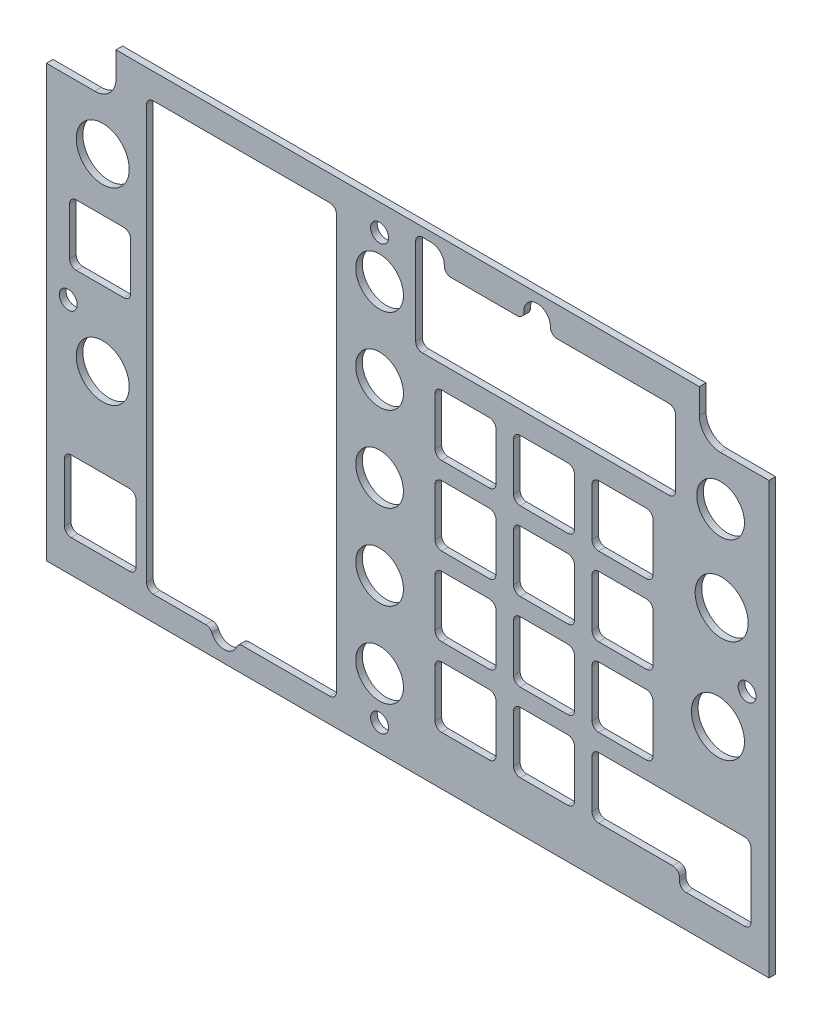
from build123d import *

# Parameters (mm, degrees)
BOSS_EXTRUDE1_DEPTH         = 1.5875
SKETCH2_R                   = 6.35
SKETCH2_R_2                 = 5.715
SKETCH2_W                   = 14.605
SKETCH2_H                   = 14.605
SKETCH2_W_2                 = 17.145
SKETCH2_H_2                 = 17.145
SKETCH2_W_3                 = 62.23
SKETCH2_H_3                 = 19.05
SKETCH2_W_4                 = 45.462
SKETCH2_H_4                 = 102.32
CUT_EXTRUDE1_DEPTH          = 2.5875
F_6_CLEARANCE_HOLE2_D       = 4.3053
F_1_4_0_25_DIAMETER_HOLE1_D = 6.35
CUT_EXTRUDE3_DEPTH          = 2.5875
FILLET1_R                   = 1.5875
FILLET2_R                   = 1.5875


with BuildPart() as part:
    # Sketch1 → Boss-Extrude1 (new body)
    with BuildSketch(Plane.XY):
        with BuildLine():
            Line((58.206752076, 169.534029068), (58.206752076, 175.566529068))
            Line((58.206752076, 175.566529068), (-81.493247924, 175.566529068))
            Line((-81.493247924, 175.566529068), (-81.493247924, 169.534029068))
            ThreePointArc((-81.493247924, 169.534029068), (-82.981145475, 165.941926619), (-86.573247924, 164.454029068))
            Line((-86.573247924, 164.454029068), (-98.161997924, 164.454029068))
            Line((-98.161997924, 164.454029068), (-98.161997924, 61.266529068))
            Line((-98.161997924, 61.266529068), (74.875502076, 61.266529068))
            Line((74.875502076, 61.266529068), (74.875502076, 164.454029068))
            Line((74.875502076, 164.454029068), (63.286752076, 164.454029068))
            ThreePointArc((63.286752076, 164.454029068), (59.694649628, 165.941926619), (58.206752076, 169.534029068))
        make_face()
    extrude(amount=BOSS_EXTRUDE1_DEPTH)

    # Sketch2 → Cut-Extrude1 (cut, through all)
    with BuildSketch(Plane.XY.offset(1.5875)):
        with Locations((-84.668247924, 152.389029068)):
            Circle(SKETCH2_R)
        with Locations((-84.668247924, 107.304029068)):
            Circle(SKETCH2_R)
        with Locations((63.540752076, 132.386529068)):
            Circle(SKETCH2_R)
        with Locations((62.651752076, 107.304029068)):
            Circle(SKETCH2_R)
        with Locations((-18.374247924, 77.776529068)):
            Circle(SKETCH2_R_2)
        with Locations((-18.374247924, 98.096529068)):
            Circle(SKETCH2_R_2)
        with Locations((-18.374247924, 118.416529068)):
            Circle(SKETCH2_R_2)
        with Locations((-18.374247924, 138.736529068)):
            Circle(SKETCH2_R_2)
        with Locations((-18.374247924, 159.056529068)):
            Circle(SKETCH2_R_2)
        with Locations((63.286752076, 152.706529068)):
            Circle(SKETCH2_R_2)
        with Locations((39.791752076, 136.704529068)):
            Rectangle(SKETCH2_W, SKETCH2_H)
        with Locations((62.004966978, 77.649529068)):
            Rectangle(SKETCH2_W_2, SKETCH2_H_2)
        with Locations((20.995752076, 136.704529068)):
            Rectangle(SKETCH2_W, SKETCH2_H)
        with Locations((2.199752076, 136.704529068)):
            Rectangle(SKETCH2_W, SKETCH2_H)
        with Locations((21.376752076, 158.929529068)):
            Rectangle(SKETCH2_W_3, SKETCH2_H_3)
        with Locations((39.791752076, 80.316529068)):
            Rectangle(SKETCH2_W, SKETCH2_H)
        with Locations((39.791752076, 99.112529068)):
            Rectangle(SKETCH2_W, SKETCH2_H)
        with Locations((39.791752076, 117.908529068)):
            Rectangle(SKETCH2_W, SKETCH2_H)
        with Locations((20.995752076, 80.316529068)):
            Rectangle(SKETCH2_W, SKETCH2_H)
        with Locations((-85.255785181, 77.63300664)):
            Rectangle(SKETCH2_W_2, SKETCH2_H_2)
        with Locations((20.995752076, 99.112529068)):
            Rectangle(SKETCH2_W, SKETCH2_H)
        with Locations((20.995752076, 117.908529068)):
            Rectangle(SKETCH2_W, SKETCH2_H)
        with Locations((2.199752076, 117.908529068)):
            Rectangle(SKETCH2_W, SKETCH2_H)
        with Locations((2.199752076, 99.112529068)):
            Rectangle(SKETCH2_W, SKETCH2_H)
        with Locations((2.199752076, 80.316529068)):
            Rectangle(SKETCH2_W, SKETCH2_H)
        with Locations((-85.303247924, 132.386529068)):
            Rectangle(SKETCH2_W, SKETCH2_H)
        with Locations((-51.442247924, 118.289529068)):
            Rectangle(SKETCH2_W_4, SKETCH2_H_4)
    extrude(amount=-CUT_EXTRUDE1_DEPTH, mode=Mode.SUBTRACT)

    # #6 Clearance Hole2 (through all)
    with Locations(Plane(origin=(-11.643247924, -6.662700632, -3.175), x_dir=(-1, 0, 0), z_dir=(0, 0, -1))):
        with Locations((-81.28, 124.6982297), (6.731, 175.8792297), (81.28, 124.6982297), (6.731, 74.2792297)):
            Hole(F_6_CLEARANCE_HOLE2_D / 2)

    # 1/4 (0.25) Diameter Hole1 (through all)
    with Locations(Plane(origin=(0, 0, 0), x_dir=(-1, 0, 0), z_dir=(0, 0, -1))):
        with Locations((55.583247924, 67.341529068), (-49.826752076, 81.946529068), (-19.346752076, 170.211529068), (6.053247924, 170.211529068)):
            Hole(F_1_4_0_25_DIAMETER_HOLE1_D / 2)

    # Sketch10 → Cut-Extrude3 (cut, through all)
    with BuildSketch(Plane(origin=(0, 0, 0), x_dir=(-1, 0, 0), z_dir=(0, 0, -1))):
        with BuildLine():
            Line((9.738247924, 168.454529068), (9.738247924, 173.386529068))
            Line((9.738247924, 173.386529068), (6.053247924, 173.386529068))
            ThreePointArc((6.053247924, 173.386529068), (8.85138123, 171.711887358), (8.697784934, 168.454529068))
            Line((8.697784934, 168.454529068), (9.738247924, 168.454529068))
        make_face()
        Polygon((-47.094252076, 87.619029068), (-47.094252076, 73.014029068), (-53.432466978, 73.014029068), (-53.432466978, 86.222029068), (-70.577466978, 86.222029068), (-70.577466978, 87.619029068), align=None)
    extrude(amount=-CUT_EXTRUDE3_DEPTH, mode=Mode.SUBTRACT)

    # Fillet1
    fillet1_edges = [part.edges().sort_by_distance(p)[0] for p in [
        (9.502252076, 106.415029068, 0.79375),
        (9.502252076, 91.810029068, 0.79375),
        (-5.102747924, 91.810029068, 0.79375),
        (-5.102747924, 106.415029068, 0.79375),
        (9.502252076, 87.619029068, 0.79375),
        (9.502252076, 73.014029068, 0.79375),
        (-5.102747924, 73.014029068, 0.79375),
        (-5.102747924, 87.619029068, 0.79375),
        (-92.605747924, 125.084029068, 0.79375),
        (-92.605747924, 139.689029068, 0.79375),
        (-78.000747924, 139.689029068, 0.79375),
        (-78.000747924, 125.084029068, 0.79375),
        (-28.711247924, 169.449529068, 0.79375),
        (-28.711247924, 67.129529068, 0.79375),
        (-74.173247924, 67.129529068, 0.79375),
        (-74.173247924, 169.449529068, 0.79375),
        (32.489252076, 73.014029068, 0.79375),
        (32.489252076, 87.619029068, 0.79375),
        (47.094252076, 106.415029068, 0.79375),
        (47.094252076, 91.810029068, 0.79375),
        (32.489252076, 91.810029068, 0.79375),
        (32.489252076, 106.415029068, 0.79375),
        (47.094252076, 125.211029068, 0.79375),
        (47.094252076, 110.606029068, 0.79375),
        (32.489252076, 110.606029068, 0.79375),
        (32.489252076, 125.211029068, 0.79375),
        (28.298252076, 144.007029068, 0.79375),
        (28.298252076, 129.402029068, 0.79375),
        (13.693252076, 129.402029068, 0.79375),
        (13.693252076, 144.007029068, 0.79375),
        (-5.102747924, 129.402029068, 0.79375),
        (-5.102747924, 144.007029068, 0.79375),
        (9.502252076, 144.007029068, 0.79375),
        (9.502252076, 129.402029068, 0.79375),
        (47.094252076, 144.007029068, 0.79375),
        (47.094252076, 129.402029068, 0.79375),
        (32.489252076, 129.402029068, 0.79375),
        (32.489252076, 144.007029068, 0.79375),
        (52.491752076, 168.454529068, 0.79375),
        (52.491752076, 149.404529068, 0.79375),
        (-9.738247924, 149.404529068, 0.79375),
        (53.432466978, 69.077029068, 0.79375),
        (70.577466978, 69.077029068, 0.79375),
        (-76.683285181, 86.20550664, 0.79375),
        (-76.683285181, 69.06050664, 0.79375),
        (-93.828285181, 69.06050664, 0.79375),
        (-93.828285181, 86.20550664, 0.79375),
        (-3.408710914, 168.454529068, 0.79375),
        (21.991289086, 168.454529068, 0.79375),
        (16.702215066, 168.454529068, 0.79375),
        (-58.751162222, 67.129529068, 0.79375),
        (-52.415333626, 67.129529068, 0.79375),
        (-9.738247924, 173.386529068, 0.79375),
        (70.577466978, 87.619029068, 0.79375),
        (28.298252076, 87.619029068, 0.79375),
        (28.298252076, 73.014029068, 0.79375),
        (13.693252076, 73.014029068, 0.79375),
        (13.693252076, 87.619029068, 0.79375),
        (28.298252076, 106.415029068, 0.79375),
        (28.298252076, 91.810029068, 0.79375),
        (13.693252076, 91.810029068, 0.79375),
        (13.693252076, 106.415029068, 0.79375),
        (28.298252076, 125.211029068, 0.79375),
        (28.298252076, 110.606029068, 0.79375),
        (13.693252076, 110.606029068, 0.79375),
        (13.693252076, 125.211029068, 0.79375),
        (-5.102747924, 110.606029068, 0.79375),
        (-5.102747924, 125.211029068, 0.79375),
        (9.502252076, 125.211029068, 0.79375),
        (9.502252076, 110.606029068, 0.79375),
    ]]
    fillet(fillet1_edges, radius=FILLET1_R)

    # Fillet2
    fillet2_edges = [part.edges().sort_by_distance(p)[0] for p in [
        (53.432466978, 73.014029068, 0.79375),
    ]]
    fillet(fillet2_edges, radius=FILLET2_R)


solid = part.part
